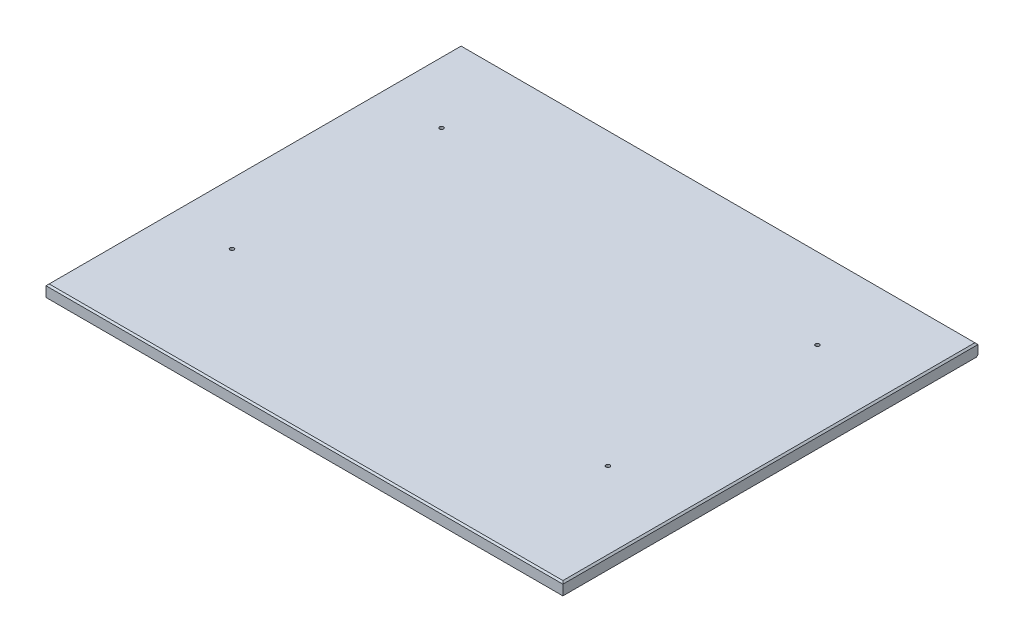
from build123d import *

# Parameters (mm, degrees)
SKETCH1_W           = 838.2
SKETCH1_H           = 673.1
BOSS_EXTRUDE1_DEPTH = 19.05
CHAMFER1_SIZE       = 2.54
CHAMFER2_SIZE       = 2.54
SKETCH2_R           = 3.175
CUT_EXTRUDE1_DEPTH  = 20.05


with BuildPart() as part:
    # Sketch1 → Boss-Extrude1 (new body)
    with BuildSketch(Plane(origin=(0, 0, 0), x_dir=(1, 0, 0), z_dir=(0, 1, 0))):
        with Locations((419.1, 336.55)):
            Rectangle(SKETCH1_W, SKETCH1_H)
    extrude(amount=BOSS_EXTRUDE1_DEPTH)

    # Chamfer1
    chamfer1_edges = [part.edges().sort_by_distance(p)[0] for p in [
        (838.2, 19.05, -336.55),
        (419.1, 19.05, -673.1),
        (0, 19.05, -336.55),
        (419.1, 19.05, 0),
    ]]
    chamfer(chamfer1_edges, length=CHAMFER1_SIZE)

    # Chamfer2
    chamfer2_edges = [part.edges().sort_by_distance(p)[0] for p in [
        (419.1, 0, -673.1),
    ]]
    chamfer(chamfer2_edges, length=CHAMFER2_SIZE)

    # Sketch2 → Cut-Extrude1 (cut, through all)
    with BuildSketch(Plane(origin=(0, 19.05, 0), x_dir=(1, 0, 0), z_dir=(0, 1, 0))):
        with Locations((101.6, 539.75)):
            Circle(SKETCH2_R)
        with Locations((101.6, 200.025)):
            Circle(SKETCH2_R)
        with Locations((711.2, 539.75)):
            Circle(SKETCH2_R)
        with Locations((711.2, 200.025)):
            Circle(SKETCH2_R)
    extrude(amount=-CUT_EXTRUDE1_DEPTH, mode=Mode.SUBTRACT)


solid = part.part
